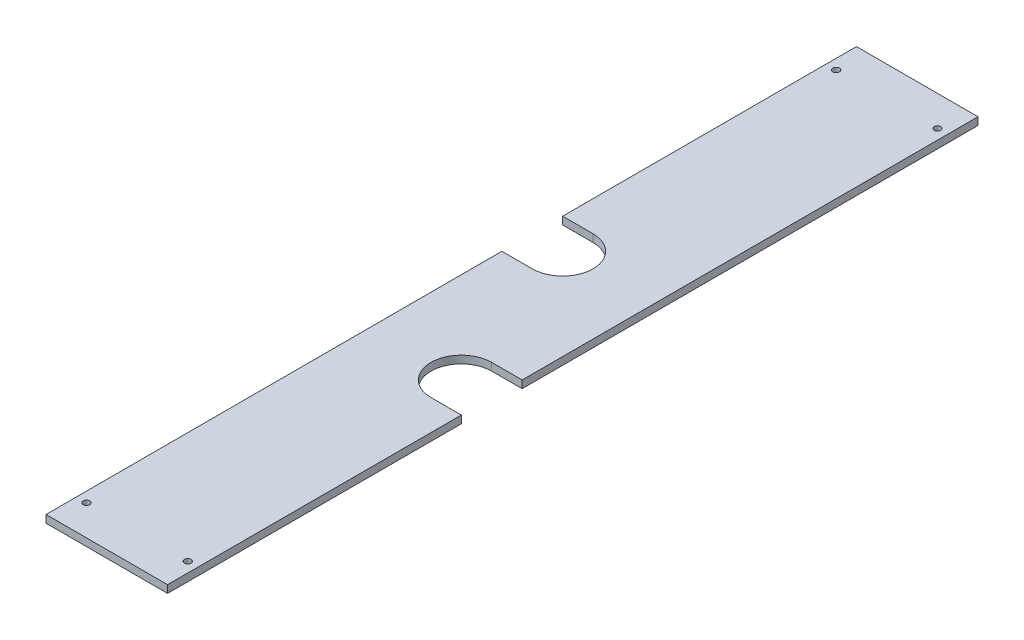
from build123d import *

# Parameters (mm, degrees)
SKETCH1_W           = 76.2
SKETCH1_H           = 4.7625
BOSS_EXTRUDE1_DEPTH = 508
CUT_EXTRUDE1_DEPTH  = 5.7625
SKETCH3_R           = 2.0828
CUT_EXTRUDE2_DEPTH  = 5.7625


with BuildPart() as part:
    # Sketch1 → Boss-Extrude1 (new body)
    with BuildSketch(Plane.XY):
        with Locations((0, 20.514000599)):
            Rectangle(SKETCH1_W, SKETCH1_H)
    extrude(amount=BOSS_EXTRUDE1_DEPTH)

    # Sketch2 → Cut-Extrude1 (cut, through all)
    with BuildSketch(Plane(origin=(0, 22.895250599, 0), x_dir=(1, 0, 0), z_dir=(0, 1, 0))):
        with BuildLine():
            Line((-19.05, -184.15), (-38.1, -184.15))
            Line((-38.1, -184.15), (-38.1, -222.25))
            Line((-38.1, -222.25), (-19.05, -222.25))
            ThreePointArc((-19.05, -222.25), (0, -203.2), (-19.05, -184.15))
        make_face()
        with BuildLine():
            Line((19.05, -323.85), (38.1, -323.85))
            Line((38.1, -323.85), (38.1, -285.75))
            Line((38.1, -285.75), (19.05, -285.75))
            ThreePointArc((19.05, -285.75), (0, -304.8), (19.05, -323.85))
        make_face()
    extrude(amount=-CUT_EXTRUDE1_DEPTH, mode=Mode.SUBTRACT)

    # Sketch3 → Cut-Extrude2 (cut, through all)
    with BuildSketch(Plane(origin=(0, 22.895250599, 0), x_dir=(1, 0, 0), z_dir=(0, 1, 0))):
        with Locations((-31.75, -488.95)):
            Circle(SKETCH3_R)
        with Locations((31.75, -19.05)):
            Circle(SKETCH3_R)
    cut_extrude2 = extrude(amount=-CUT_EXTRUDE2_DEPTH, mode=Mode.SUBTRACT)

    # Mirror1: Cut-Extrude2 across plane
    add(cut_extrude2.mirror(Plane.XY.offset(254)), mode=Mode.SUBTRACT)


solid = part.part
